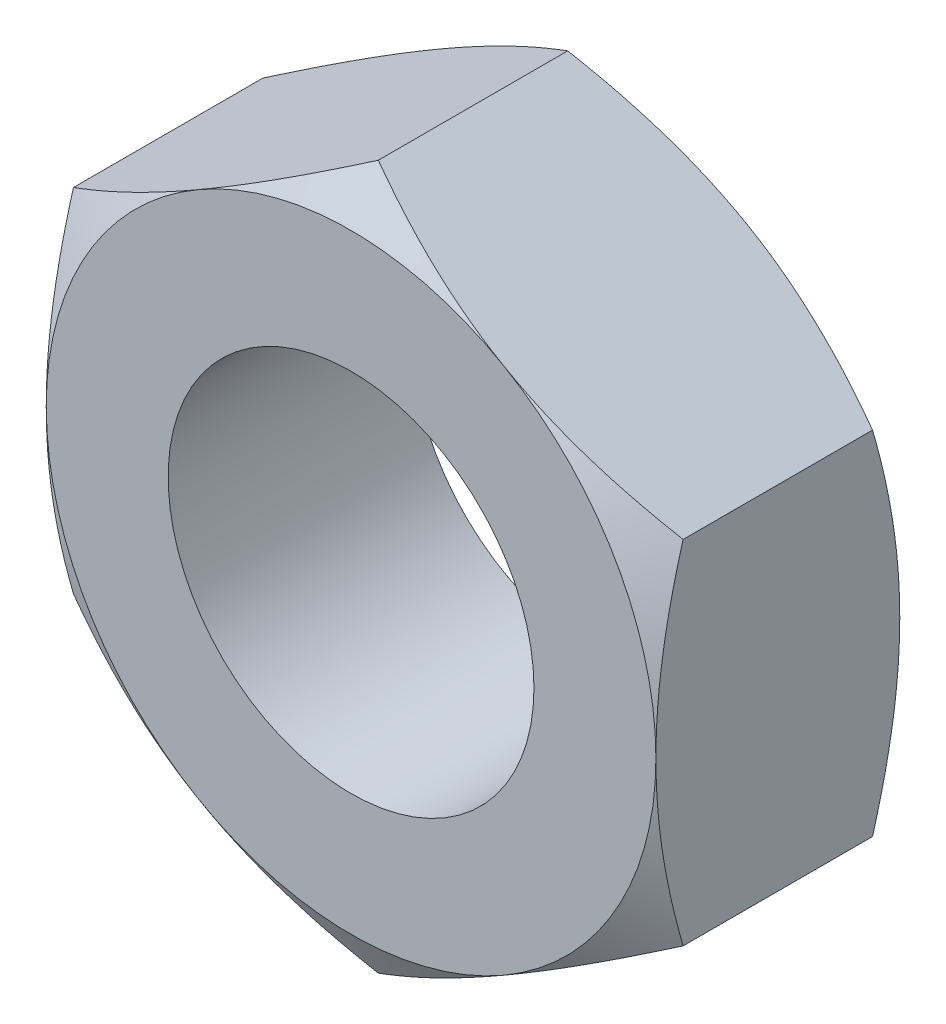
from build123d import *

# Parameters (mm, degrees)
SKETCH1_R           = 1.5
BOSS_EXTRUDE1_DEPTH = 2
SKETCH2_OUTSIDE_W   = 15.508
SKETCH2_OUTSIDE_H   = 16.282
SKETCH2_OUTSIDE_R   = 2.5
CUT_EXTRUDE1_DEPTH  = 2
CUT_EXTRUDE1_TAPER  = 60
SKETCH3_OUTSIDE_W   = 15.508
SKETCH3_OUTSIDE_H   = 16.282
SKETCH3_OUTSIDE_R   = 2.5
CUT_EXTRUDE2_DEPTH  = 2
CUT_EXTRUDE2_TAPER  = 60


with BuildPart() as part:
    # Sketch1 → Boss-Extrude1 (new body)
    with BuildSketch(Plane.XY):
        Polygon((0, -2.886751346), (2.5, -1.443375673), (2.5, 1.443375673), (0, 2.886751346), (-2.5, 1.443375673), (-2.5, -1.443375673), align=None)
        Circle(SKETCH1_R, mode=Mode.SUBTRACT)
    extrude(amount=BOSS_EXTRUDE1_DEPTH)

    # Sketch2 outside → Cut-Extrude1 (cut)
    with BuildSketch(Plane.XY.offset(2)):
        Rectangle(SKETCH2_OUTSIDE_W, SKETCH2_OUTSIDE_H)
        Circle(SKETCH2_OUTSIDE_R, mode=Mode.SUBTRACT)
    extrude(amount=-CUT_EXTRUDE1_DEPTH, taper=CUT_EXTRUDE1_TAPER, mode=Mode.SUBTRACT)

    # Sketch3 outside → Cut-Extrude2 (cut)
    with BuildSketch(Plane(origin=(0, 0, 0), x_dir=(-1, 0, 0), z_dir=(0, 0, -1))):
        Rectangle(SKETCH3_OUTSIDE_W, SKETCH3_OUTSIDE_H)
        Circle(SKETCH3_OUTSIDE_R, mode=Mode.SUBTRACT)
    extrude(amount=-CUT_EXTRUDE2_DEPTH, taper=CUT_EXTRUDE2_TAPER, mode=Mode.SUBTRACT)


solid = part.part
